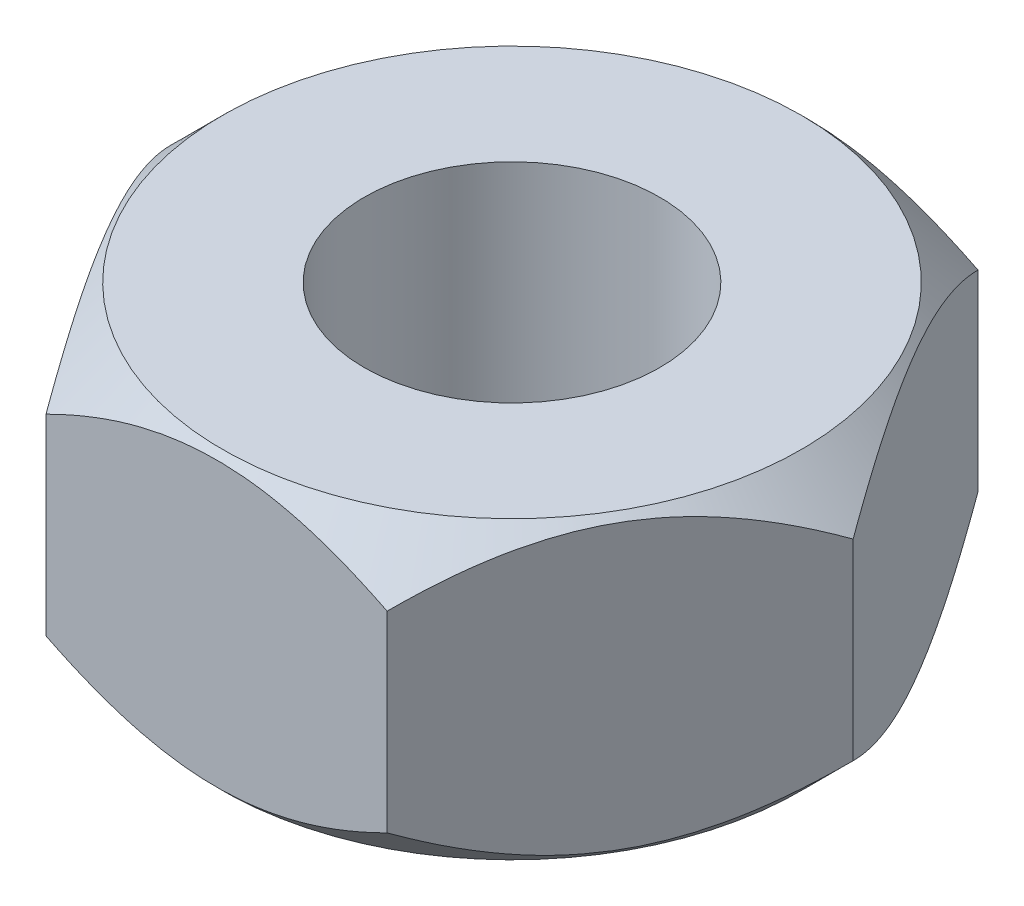
from build123d import *

# Parameters (mm, degrees)
SKETCH1_R           = 2
BOSS_EXTRUDE1_DEPTH = 2


with BuildPart() as part:
    # Sketch1 → Boss-Extrude1 (new body, symmetric)
    with BuildSketch(Plane(origin=(0, 0, 0), x_dir=(1, 0, 0), z_dir=(0, 1, 0))):
        Polygon((2.309401077, 4), (-2.309401077, 4), (-4.618802154, 0), (-2.309401077, -4), (2.309401077, -4), (4.618802154, 0), align=None)
        Circle(SKETCH1_R, mode=Mode.SUBTRACT)
    extrude(amount=BOSS_EXTRUDE1_DEPTH, both=True)

    # Sketch2 → Cut-Revolve1 (revolve, cut)
    with BuildSketch(Plane.XY):
        Polygon((-4.618802154, 1.3), (-3.918802154, 2), (-4.618802154, 2), align=None)
    cut_revolve1 = revolve(axis=Axis((0, 0, 0), (0, 1, 0)), mode=Mode.SUBTRACT)

    # Mirror1: Cut-Revolve1 across plane
    add(cut_revolve1.mirror(Plane.ZX), mode=Mode.SUBTRACT)


solid = part.part
